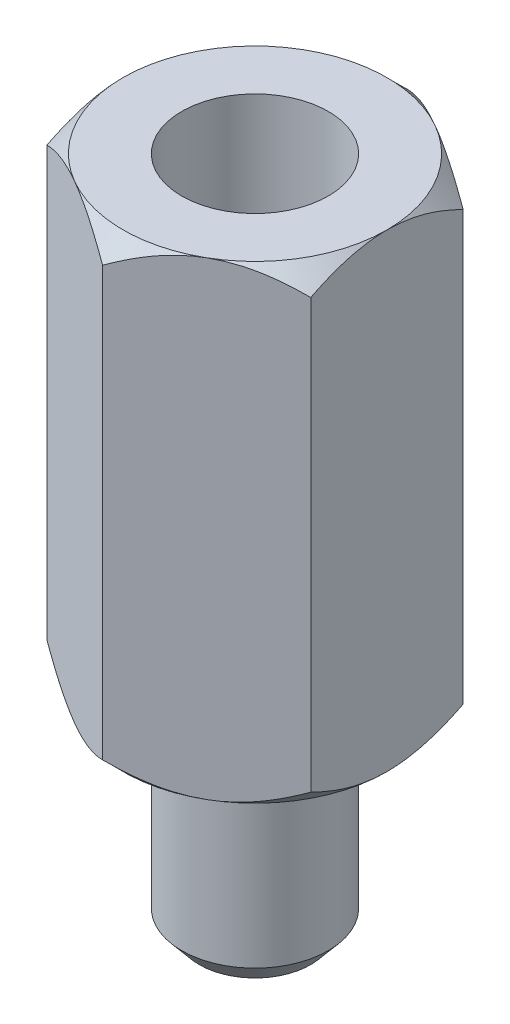
from build123d import *

# Parameters (mm, degrees)
SKETCH1_R           = 1.25
BOSS_EXTRUDE1_DEPTH = 3.5
BOSS_EXTRUDE2_DEPTH = 8
SKETCH3_R           = 1.25
CUT_EXTRUDE1_DEPTH  = 4.8
SKETCH5_OUTSIDE_W   = 34.18
SKETCH5_OUTSIDE_H   = 34.876
SKETCH5_OUTSIDE_R   = 2.25
CUT_EXTRUDE2_DEPTH  = 12.5
CUT_EXTRUDE2_TAPER  = 45
SKETCH6_OUTSIDE_W   = 27.18
SKETCH6_OUTSIDE_H   = 27.876
SKETCH6_OUTSIDE_R   = 2.25
CUT_EXTRUDE3_DEPTH  = 9
CUT_EXTRUDE3_TAPER  = 45
CHAMFER1_SIZE       = 0.3
CHAMFER1_SIZE2      = 0.357526078


with BuildPart() as part:
    # Sketch1 → Boss-Extrude1 (new body)
    with BuildSketch(Plane(origin=(0, 0, 0), x_dir=(1, 0, 0), z_dir=(0, 1, 0))):
        Circle(SKETCH1_R)
    extrude(amount=BOSS_EXTRUDE1_DEPTH)

    # Sketch2 → Boss-Extrude2 (add)
    with BuildSketch(Plane(origin=(0, 3.5, 0), x_dir=(1, 0, 0), z_dir=(0, 1, 0))):
        Polygon((2.25, -1.299038106), (2.25, 1.299038106), (0, 2.598076211), (-2.25, 1.299038106), (-2.25, -1.299038106), (0, -2.598076211), align=None)
    extrude(amount=BOSS_EXTRUDE2_DEPTH)

    # Sketch3 → Cut-Extrude1 (cut)
    with BuildSketch(Plane(origin=(0, 11.5, 0), x_dir=(1, 0, 0), z_dir=(0, 1, 0))):
        Circle(SKETCH3_R)
    extrude(amount=-CUT_EXTRUDE1_DEPTH, mode=Mode.SUBTRACT)

    # Sketch5 outside → Cut-Extrude2 (cut, through all)
    with BuildSketch(Plane(origin=(0, 11.5, 0), x_dir=(1, 0, 0), z_dir=(0, 1, 0))):
        Rectangle(SKETCH5_OUTSIDE_W, SKETCH5_OUTSIDE_H)
        Circle(SKETCH5_OUTSIDE_R, mode=Mode.SUBTRACT)
    extrude(amount=-CUT_EXTRUDE2_DEPTH, taper=CUT_EXTRUDE2_TAPER, mode=Mode.SUBTRACT)

    # Sketch6 outside → Cut-Extrude3 (cut, through all)
    with BuildSketch(Plane.XZ.offset(-3.5)):
        Rectangle(SKETCH6_OUTSIDE_W, SKETCH6_OUTSIDE_H)
        Circle(SKETCH6_OUTSIDE_R, mode=Mode.SUBTRACT)
    extrude(amount=-CUT_EXTRUDE3_DEPTH, taper=CUT_EXTRUDE3_TAPER, mode=Mode.SUBTRACT)

    # Chamfer1
    chamfer1_edges = [part.edges().sort_by_distance(p)[0] for p in [
        (-1.25, 0, 0),
    ]]
    chamfer1_side = [part.faces().sort_by_distance(p)[0] for p in [
        (0, 0, 0),
    ]]
    chamfer(chamfer1_edges, length=CHAMFER1_SIZE, length2=CHAMFER1_SIZE2, reference=chamfer1_side[0])


solid = part.part
